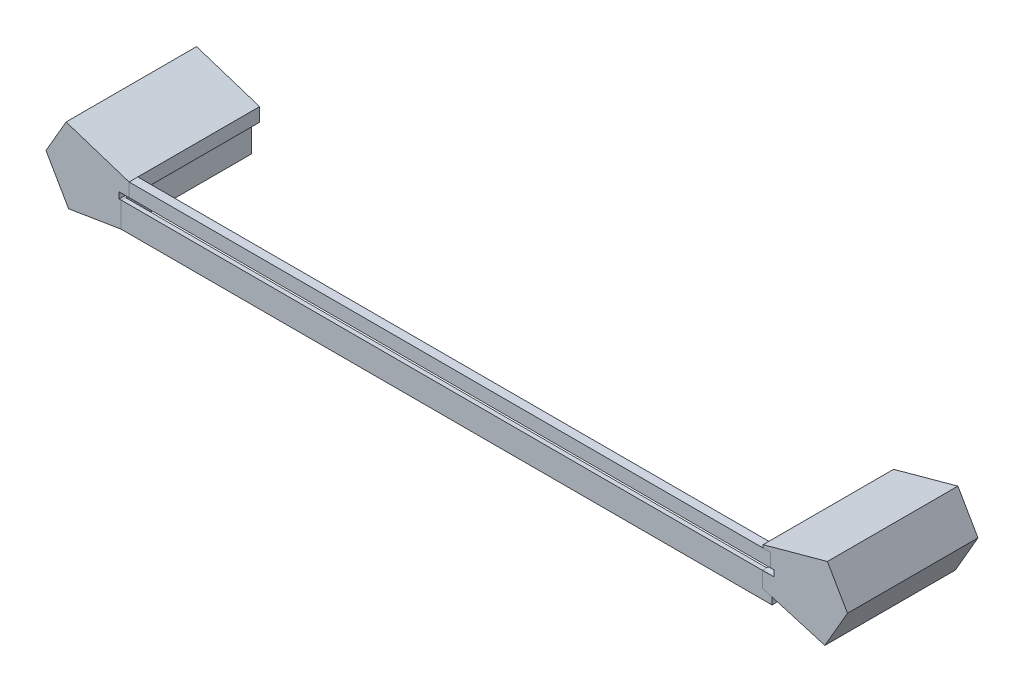
from build123d import *

# Parameters (mm, degrees)
RESSALTO_EXTRUS_O1_DEPTH   = 30
RESSALTO_EXTRUS_O1_2_DEPTH = 30
ESBO_O2_W                  = 147.444524977
ESBO_O2_H                  = 3.112709989
RESSALTO_EXTRUS_O2_DEPTH   = 2
ESBO_O3_W                  = 149.611840442
ESBO_O3_H                  = 5.798686857
RESSALTO_EXTRUS_O3_DEPTH   = 1


with BuildPart() as part:
    # Esboço1 → Ressalto-extrusão1 (new body)
    with BuildSketch(Plane.XY):
        Polygon((-92.11, 0), (-87.491197846, 8), (-73.015040819, 3.288652645), (-73.015040819, 0.175942656), (-75.277091977, 0.173187386), (-75.275386722, -1.226811575), (-74.840853313, -1.226282296), (-74.840853313, -7.024969153), (-86.913847577, -9), align=None)
    extrude(amount=RESSALTO_EXTRUS_O1_DEPTH)


with BuildPart() as body_2:
    # Esboço1 → Ressalto-extrus_o1 2 (new body)
    with BuildSketch(Plane.XY):
        Polygon((92.11, 0), (87.491197846, 8), (72.7082274, 3.953695686), (72.7082274, 0.208287179), (75.276894, 0.208287179), (75.276894, -1.191712821), (72.562052582, -1.191712821), (72.562052582, -4.789407208), (86.913847577, -9), align=None)
    extrude(amount=RESSALTO_EXTRUS_O1_2_DEPTH)


with BuildPart() as body_3:
    # Esboço2 → Ressalto-extrusão2 (new body)
    with BuildSketch(Plane.XY.offset(30)):
        with Locations((0.70722167, 1.732297651)):
            Rectangle(ESBO_O2_W, ESBO_O2_H)
    extrude(amount=-RESSALTO_EXTRUS_O2_DEPTH)


with BuildPart() as body_4:
    # Esboço3 → Ressalto-extrusão3 (new body)
    with BuildSketch(Plane.XY.offset(30)):
        with Locations((-0.034933092, -4.125625725)):
            Rectangle(ESBO_O3_W, ESBO_O3_H)
    extrude(amount=-RESSALTO_EXTRUS_O3_DEPTH)


solid = Compound([part.part, body_2.part, body_3.part, body_4.part])
